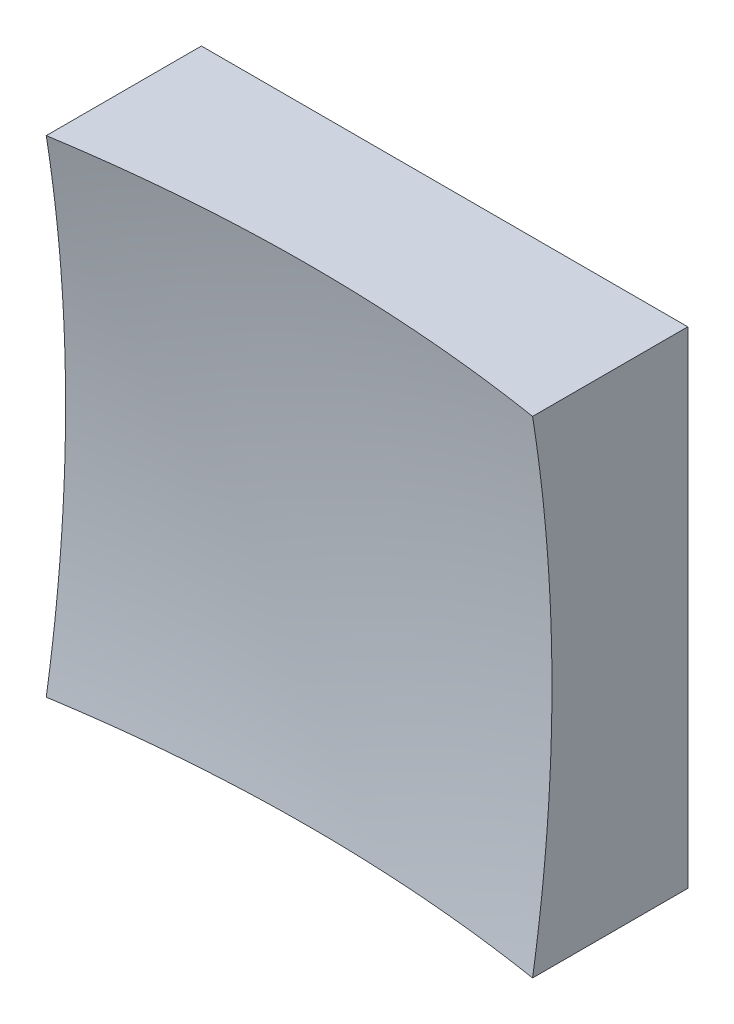
from build123d import *

# Parameters (mm, degrees)
SKETCH_1_W      = 25
SKETCH_1_H      = 25
EXTRUDE_1_DEPTH = 20


with BuildPart() as part:
    # 草图1 → 凸台-拉伸1 (new body)
    with BuildSketch(Plane.XY):
        Rectangle(SKETCH_1_W, SKETCH_1_H)
    extrude(amount=EXTRUDE_1_DEPTH)

    # 草图2 → 切除-旋转2 (revolve, cut)
    with BuildSketch(Plane(origin=(0, 0, 0), x_dir=(1, 0, 0), z_dir=(0, 1, 0))):
        with BuildLine():
            Line((77.987636945, -68.169450829), (0, -68.169450829))
            Line((0, -68.169450829), (0, -6))
            ThreePointArc((0, -6), (49.867605047, -23.444249131), (77.987636945, -68.169450829))
        make_face()
    revolve(axis=Axis((0, 0, 68.169450829), (0, 0, -1)), mode=Mode.SUBTRACT)


solid = part.part
